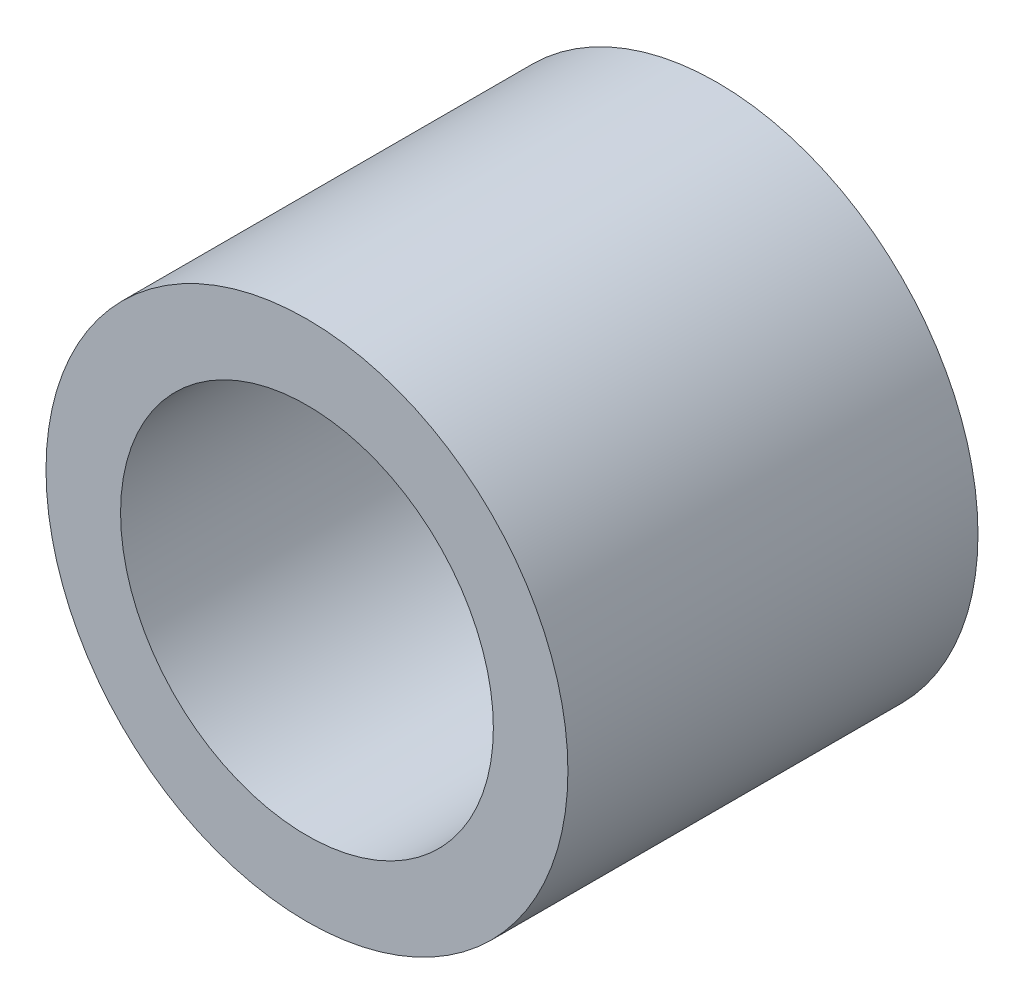
from build123d import *

# Parameters (mm, degrees)
SKETCH1_R          = 7
SKETCH1_R_2        = 5
BASE_EXTRUDE_DEPTH = 11


with BuildPart() as part:
    # Sketch1 → Base-Extrude (new body)
    with BuildSketch(Plane.XY):
        Circle(SKETCH1_R)
        Circle(SKETCH1_R_2, mode=Mode.SUBTRACT)
    extrude(amount=BASE_EXTRUDE_DEPTH)


solid = part.part
